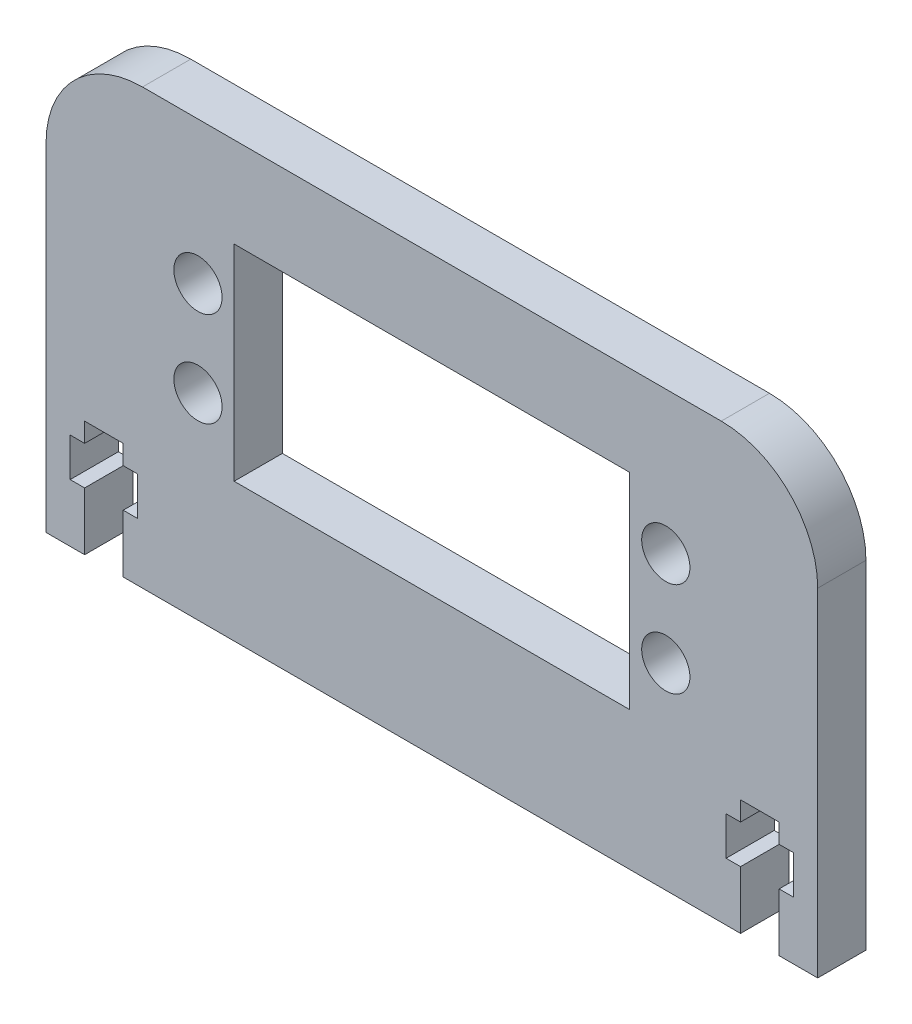
from build123d import *

# Parameters (mm, degrees)
SKETCH1_W           = 80
SKETCH1_H           = 45
BOSS_EXTRUDE1_DEPTH = 5
SKETCH2_R           = 2.5
SKETCH2_W           = 41
SKETCH2_H           = 21.3
CUT_EXTRUDE1_DEPTH  = 10
CUT_EXTRUDE2_DEPTH  = 10
FILLET1_R           = 10


with BuildPart() as part:
    # Sketch1 → Boss-Extrude1 (new body)
    with BuildSketch(Plane.XY):
        Rectangle(SKETCH1_W, SKETCH1_H)
    extrude(amount=BOSS_EXTRUDE1_DEPTH)

    # Sketch2 → Cut-Extrude1 (cut)
    with BuildSketch(Plane.XY.offset(5)):
        with Locations((-24.25, -2.1)):
            Circle(SKETCH2_R)
        with Locations((-24.25, 7.72372371)):
            Circle(SKETCH2_R)
        with Locations((24.25, 7.72372371)):
            Circle(SKETCH2_R)
        with Locations((24.25, -2.1)):
            Circle(SKETCH2_R)
        with Locations((0, 2.5)):
            Rectangle(SKETCH2_W, SKETCH2_H)
    extrude(amount=-CUT_EXTRUDE1_DEPTH, mode=Mode.SUBTRACT)

    # Sketch3 → Cut-Extrude2 (cut)
    with BuildSketch(Plane.XY.offset(5)):
        Polygon((-36, -16.5), (-36, -22.5), (-34, -22.5), (-34, -10.5), (-36, -10.5), (-36, -12.5), (-37.5, -12.5), (-37.5, -16.5), align=None)
        Polygon((-34, -10.5), (-34, -22.5), (-32, -22.5), (-32, -16.5), (-30.5, -16.5), (-30.5, -12.5), (-32, -12.5), (-32, -10.5), align=None)
        Polygon((32, -16.5), (32, -22.5), (34, -22.5), (34, -10.5), (32, -10.5), (32, -12.5), (30.5, -12.5), (30.5, -16.5), align=None)
        Polygon((34, -10.5), (34, -22.5), (36, -22.5), (36, -16.5), (37.5, -16.5), (37.5, -12.5), (36, -12.5), (36, -10.5), align=None)
    extrude(amount=-CUT_EXTRUDE2_DEPTH, mode=Mode.SUBTRACT)

    # Fillet1
    fillet1_edges = [part.edges().sort_by_distance(p)[0] for p in [
        (-40, 22.5, 2.5),
        (40, 22.5, 2.5),
    ]]
    fillet(fillet1_edges, radius=FILLET1_R)


solid = part.part
